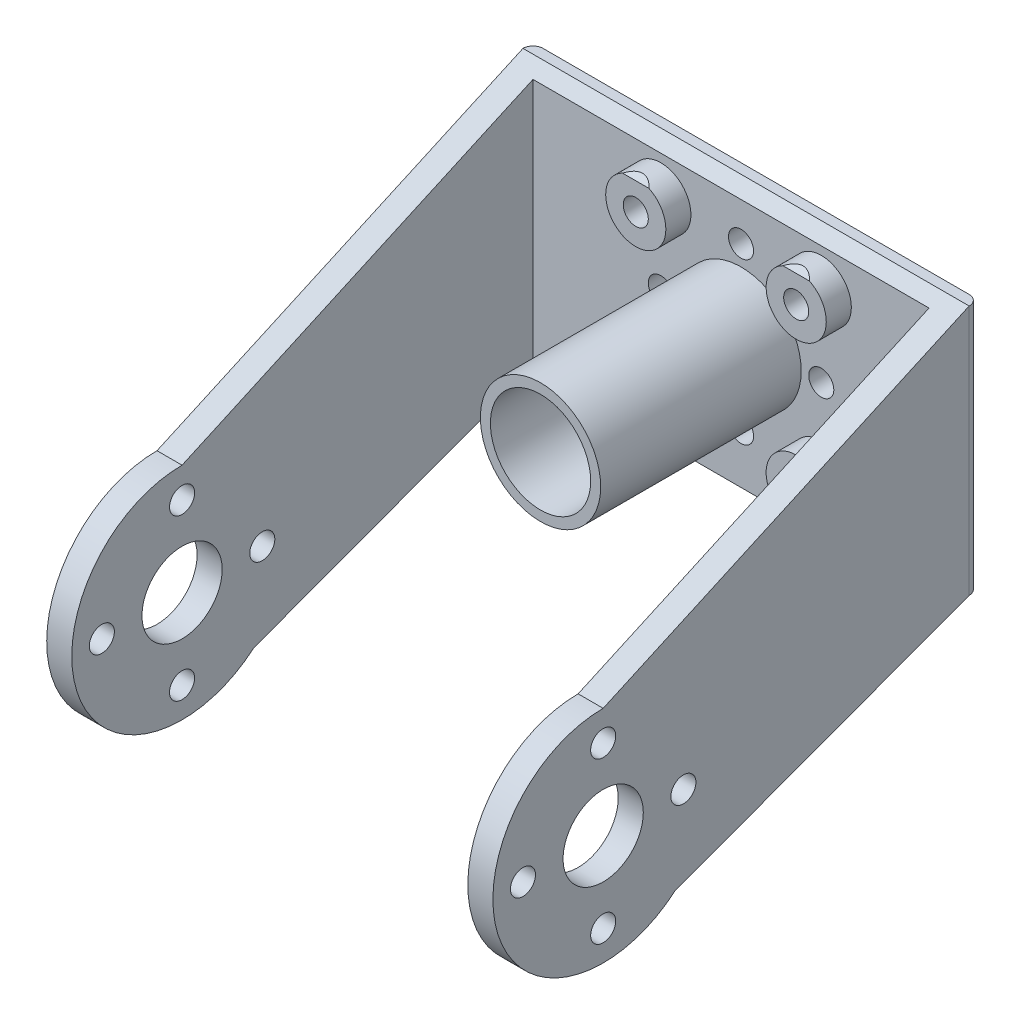
from build123d import *

# Parameters (mm, degrees)
SKETCH1_W           = 44.5
SKETCH1_H           = 40
BOSS_EXTRUDE1_DEPTH = 48.5
SKETCH2_W           = 39.5
SKETCH2_H           = 40
CUT_EXTRUDE1_DEPTH  = 46
FILLET1_R           = 1
SKETCH3_R           = 3
BOSS_EXTRUDE2_DEPTH = 2.5
SKETCH5_R           = 1.25
SKETCH5_R_2         = 5
CUT_EXTRUDE5_DEPTH  = 6
SKETCH7_R           = 4
CUT_EXTRUDE7_DEPTH  = 44.5
SKETCH8_R           = 1.25
CUT_EXTRUDE8_DEPTH  = 44.5
SKETCH9_W           = 44.5
SKETCH9_H           = 15
CUT_EXTRUDE9_DEPTH  = 10
SKETCH10_R          = 6
SKETCH10_R_2        = 5
EXTRUDE_THIN1_DEPTH = 20


with BuildPart() as part:
    # Sketch1 → Boss-Extrude1 (new body)
    with BuildSketch(Plane.XY):
        with Locations((22.25, 20)):
            Rectangle(SKETCH1_W, SKETCH1_H)
    extrude(amount=BOSS_EXTRUDE1_DEPTH)

    # Sketch2 → Cut-Extrude1 (cut)
    with BuildSketch(Plane.XY.offset(48.5)):
        with Locations((22.25, 20)):
            Rectangle(SKETCH2_W, SKETCH2_H)
    extrude(amount=-CUT_EXTRUDE1_DEPTH, mode=Mode.SUBTRACT)

    # Fillet1
    fillet1_edges = [part.edges().sort_by_distance(p)[0] for p in [
        (44.5, 20, 0),
        (0, 20, 0),
    ]]
    fillet(fillet1_edges, radius=FILLET1_R)

    # Sketch3 → Boss-Extrude2 (add)
    with BuildSketch(Plane.XY.offset(2.5)):
        with Locations((15.25, 19.5)):
            Circle(SKETCH3_R)
        with Locations((31.25, 19.5)):
            Circle(SKETCH3_R)
        with Locations((31.25, 35.5)):
            Circle(SKETCH3_R)
        with Locations((15.25, 35.5)):
            Circle(SKETCH3_R)
    extrude(amount=BOSS_EXTRUDE2_DEPTH)

    # Sketch5 → Cut-Extrude5 (cut)
    with BuildSketch(Plane.XY.offset(5)):
        with Locations((23.25, 35.5)):
            Circle(SKETCH5_R)
        with Locations((31.25, 35.5)):
            Circle(SKETCH5_R)
        with Locations((15.25, 35.5)):
            Circle(SKETCH5_R)
        with Locations((23.25, 27.5)):
            Circle(SKETCH5_R_2)
        with Locations((31.25, 27.5)):
            Circle(SKETCH5_R)
        with Locations((23.25, 19.5)):
            Circle(SKETCH5_R)
        with Locations((31.25, 19.5)):
            Circle(SKETCH5_R)
        with Locations((15.25, 27.5)):
            Circle(SKETCH5_R)
        with Locations((15.25, 19.5)):
            Circle(SKETCH5_R)
    extrude(amount=-CUT_EXTRUDE5_DEPTH, mode=Mode.SUBTRACT)

    # Sketch7 → Cut-Extrude7 (cut)
    with BuildSketch(Plane(origin=(44.5, 0, 0), x_dir=(0, 0, -1), z_dir=(1, 0, 0))):
        with Locations((-37.5, 12.5)):
            Circle(SKETCH7_R)
        with BuildLine():
            Line((-48.5, 40), (-48.5, 12.500000045))
            ThreePointArc((-48.5, 12.500000045), (-45.278174577, 20.278174609), (-37.5, 23.5))
            Line((-37.5, 23.5), (-1, 40))
            Line((-1, 40), (-48.5, 40))
        make_face()
        with BuildLine():
            ThreePointArc((-30.342192143, 4.147408386), (-33.684145427, 2.183059859), (-37.5, 1.5))
            ThreePointArc((-37.5, 1.5), (-45.278174609, 4.721825423), (-48.5, 12.500000045))
            Line((-48.5, 12.500000045), (-48.5, 0))
            Line((-48.5, 0), (-1, 0))
            Line((-1, 0), (-1, 15))
            Line((-1, 15), (-30.342192143, 4.147408386))
        make_face()
    extrude(amount=-CUT_EXTRUDE7_DEPTH, mode=Mode.SUBTRACT)

    # Sketch8 → Cut-Extrude8 (cut)
    with BuildSketch(Plane(origin=(44.5, 0, 0), x_dir=(0, 0, -1), z_dir=(1, 0, 0))):
        with Locations((-45.5, 12.5)):
            Circle(SKETCH8_R)
        with Locations((-37.5, 20.5)):
            Circle(SKETCH8_R)
        with Locations((-37.5, 4.5)):
            Circle(SKETCH8_R)
        with Locations((-29.5, 12.5)):
            Circle(SKETCH8_R)
    extrude(amount=-CUT_EXTRUDE8_DEPTH, mode=Mode.SUBTRACT)

    # Sketch9 → Cut-Extrude9 (cut)
    with BuildSketch(Plane.XY.offset(1)):
        with Locations((22.25, 7.5)):
            Rectangle(SKETCH9_W, SKETCH9_H)
    extrude(amount=-CUT_EXTRUDE9_DEPTH, mode=Mode.SUBTRACT)

    # Sketch10 → Extrude-Thin1 (add)
    with BuildSketch(Plane.XY.offset(2.5)):
        with Locations((23.25, 27.5)):
            Circle(SKETCH10_R)
        with Locations((23.25, 27.5)):
            Circle(SKETCH10_R_2, mode=Mode.SUBTRACT)
    extrude(amount=EXTRUDE_THIN1_DEPTH)


solid = part.part
